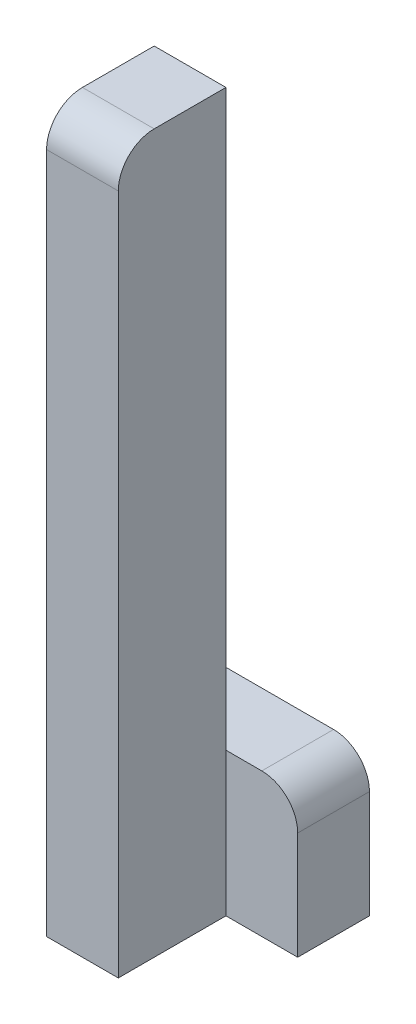
from build123d import *

# Parameters (mm, degrees)
SKETCH1_W           = 20
SKETCH1_H           = 200
BOSS_EXTRUDE1_DEPTH = 30
SKETCH2_W           = 40
SKETCH2_H           = 40
BOSS_EXTRUDE2_DEPTH = 20
FILLET1_R           = 10


with BuildPart() as part:
    # Sketch1 → Boss-Extrude1 (new body)
    with BuildSketch(Plane.XY):
        with Locations((-20, -100)):
            Rectangle(SKETCH1_W, SKETCH1_H)
    extrude(amount=BOSS_EXTRUDE1_DEPTH)

    # Sketch2 → Boss-Extrude2 (add)
    with BuildSketch(Plane.XY):
        with Locations((-10, -180)):
            Rectangle(SKETCH2_W, SKETCH2_H)
    extrude(amount=-BOSS_EXTRUDE2_DEPTH)

    # Fillet1
    fillet1_edges = [part.edges().sort_by_distance(p)[0] for p in [
        (10, -160, -10),
        (-20, 0, 30),
    ]]
    fillet(fillet1_edges, radius=FILLET1_R)


solid = part.part
